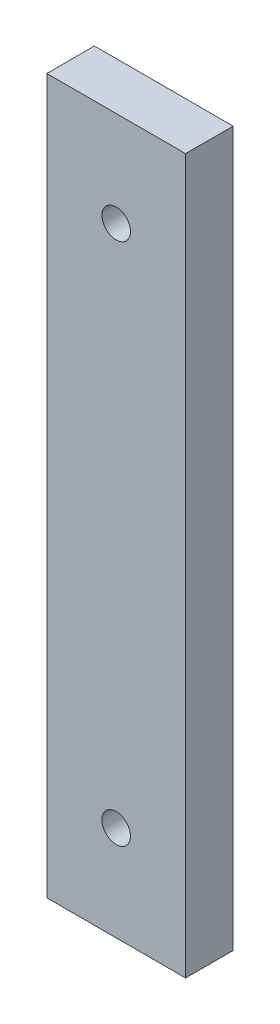
from build123d import *

# Parameters (mm, degrees)
SKETCH1_W           = 29.157667386
SKETCH1_H           = 150
SKETCH1_R           = 3
BOSS_EXTRUDE1_DEPTH = 10


with BuildPart() as part:
    # Sketch1 → Boss-Extrude1 (new body)
    with BuildSketch(Plane.XY):
        Rectangle(SKETCH1_W, SKETCH1_H)
        with Locations((0, 55)):
            Circle(SKETCH1_R, mode=Mode.SUBTRACT)
        with Locations((0, -55)):
            Circle(SKETCH1_R, mode=Mode.SUBTRACT)
    extrude(amount=BOSS_EXTRUDE1_DEPTH)


solid = part.part
